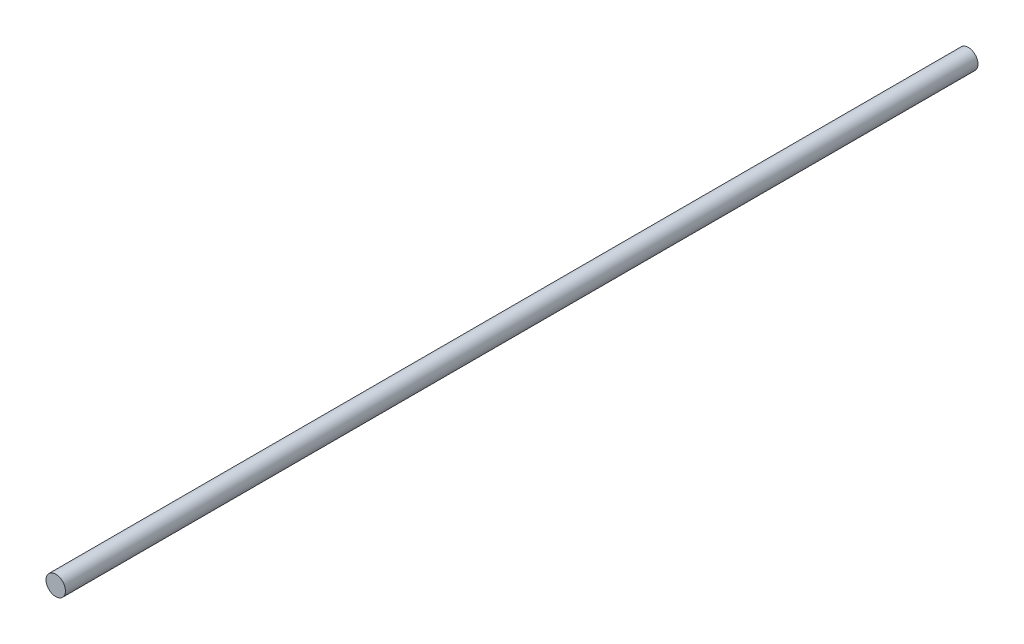
from build123d import *

# Parameters (mm, degrees)
ESBO_O1_R                = 4
RESSALTO_EXTRUS_O1_DEPTH = 375


with BuildPart() as part:
    # Esboço1 → Ressalto-extrusão1 (new body)
    with BuildSketch(Plane.XY):
        with Locations((-48.875298619, 81.407156415)):
            Circle(ESBO_O1_R)
    extrude(amount=RESSALTO_EXTRUS_O1_DEPTH)


solid = part.part
